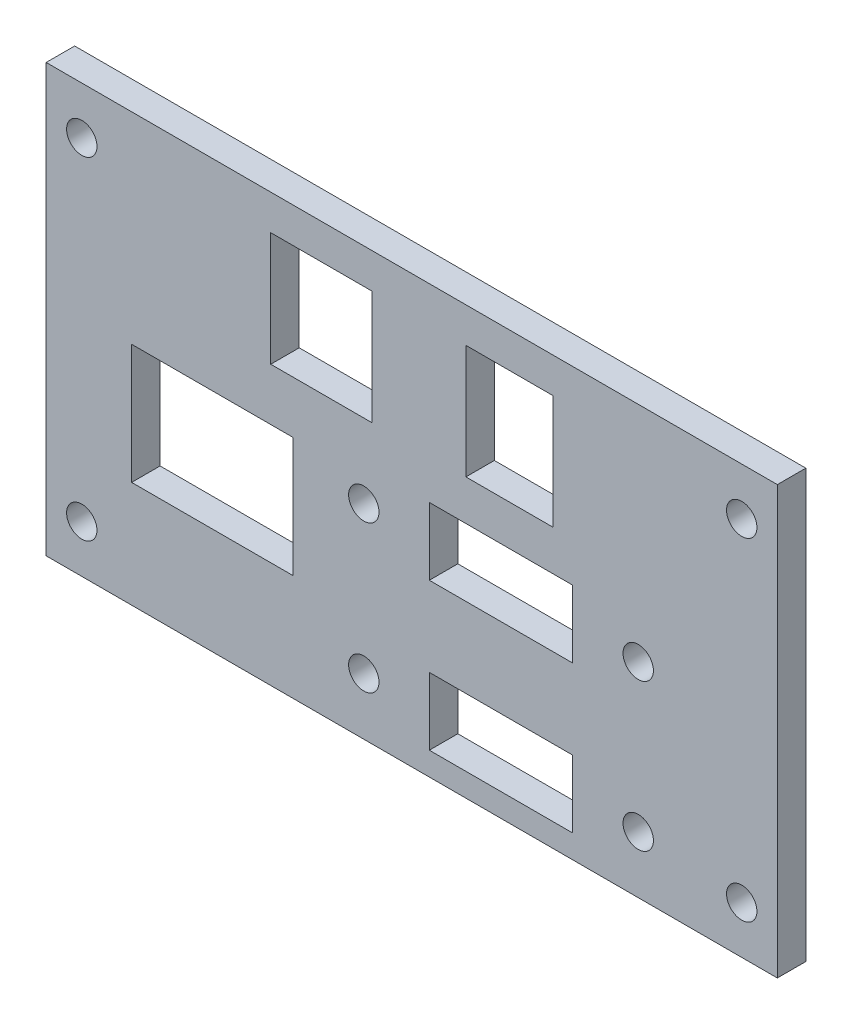
from build123d import *

# Parameters (mm, degrees)
CROQUIS1_W              = 77
CROQUIS1_H              = 45
SALIENTE_EXTRUIR1_DEPTH = 3
CORTAR_EXTRUIR1_REACH   = 5
CROQUIS2_R              = 1.6
CROQUIS2_W              = 17
CROQUIS2_H              = 12.6
CROQUIS2_W_2            = 10.65
CROQUIS2_H_2            = 12
CROQUIS2_W_3            = 9.15
CROQUIS2_W_4            = 15.1
CROQUIS2_H_3            = 7.1


with BuildPart() as part:
    # Croquis1 → Saliente-Extruir1 (new body)
    with BuildSketch(Plane.XY):
        with Locations((38.5, 22.5)):
            Rectangle(CROQUIS1_W, CROQUIS1_H)
    extrude(amount=SALIENTE_EXTRUIR1_DEPTH)

    # Croquis2 → Cortar-Extruir1 (cut, up to next)
    with BuildSketch(Plane.XY.offset(3), mode=Mode.PRIVATE) as cortar_extruir1_sk1:
        with Locations((3.75, 40)):
            Circle(CROQUIS2_R)
    cortar_extruir1_tool1 = extrude(cortar_extruir1_sk1.sketch, amount=-CORTAR_EXTRUIR1_REACH, mode=Mode.PRIVATE) & part.part
    add(cortar_extruir1_tool1.solids().sort_by_distance((3.75, 40, 3))[0], mode=Mode.SUBTRACT)
    # Croquis2 → Cortar-Extruir1 (cut, up to next)
    with BuildSketch(Plane.XY.offset(3), mode=Mode.PRIVATE) as cortar_extruir1_sk2:
        with Locations((3.75, 5)):
            Circle(CROQUIS2_R)
    cortar_extruir1_tool2 = extrude(cortar_extruir1_sk2.sketch, amount=-CORTAR_EXTRUIR1_REACH, mode=Mode.PRIVATE) & part.part
    add(cortar_extruir1_tool2.solids().sort_by_distance((3.75, 5, 3))[0], mode=Mode.SUBTRACT)
    # Croquis2 → Cortar-Extruir1 (cut, up to next)
    with BuildSketch(Plane.XY.offset(3), mode=Mode.PRIVATE) as cortar_extruir1_sk3:
        with Locations((73.25, 5)):
            Circle(CROQUIS2_R)
    cortar_extruir1_tool3 = extrude(cortar_extruir1_sk3.sketch, amount=-CORTAR_EXTRUIR1_REACH, mode=Mode.PRIVATE) & part.part
    add(cortar_extruir1_tool3.solids().sort_by_distance((73.25, 5, 3))[0], mode=Mode.SUBTRACT)
    # Croquis2 → Cortar-Extruir1 (cut, up to next)
    with BuildSketch(Plane.XY.offset(3), mode=Mode.PRIVATE) as cortar_extruir1_sk4:
        with Locations((73.25, 40)):
            Circle(CROQUIS2_R)
    cortar_extruir1_tool4 = extrude(cortar_extruir1_sk4.sketch, amount=-CORTAR_EXTRUIR1_REACH, mode=Mode.PRIVATE) & part.part
    add(cortar_extruir1_tool4.solids().sort_by_distance((73.25, 40, 3))[0], mode=Mode.SUBTRACT)
    # Croquis2 → Cortar-Extruir1 (cut, up to next)
    with BuildSketch(Plane.XY.offset(3), mode=Mode.PRIVATE) as cortar_extruir1_sk5:
        with Locations((33.45, 21.5)):
            Circle(CROQUIS2_R)
    cortar_extruir1_tool5 = extrude(cortar_extruir1_sk5.sketch, amount=-CORTAR_EXTRUIR1_REACH, mode=Mode.PRIVATE) & part.part
    add(cortar_extruir1_tool5.solids().sort_by_distance((33.45, 21.5, 3))[0], mode=Mode.SUBTRACT)
    # Croquis2 → Cortar-Extruir1 (cut, up to next)
    with BuildSketch(Plane.XY.offset(3), mode=Mode.PRIVATE) as cortar_extruir1_sk6:
        with Locations((33.45, 6)):
            Circle(CROQUIS2_R)
    cortar_extruir1_tool6 = extrude(cortar_extruir1_sk6.sketch, amount=-CORTAR_EXTRUIR1_REACH, mode=Mode.PRIVATE) & part.part
    add(cortar_extruir1_tool6.solids().sort_by_distance((33.45, 6, 3))[0], mode=Mode.SUBTRACT)
    # Croquis2 → Cortar-Extruir1 (cut, up to next)
    with BuildSketch(Plane.XY.offset(3), mode=Mode.PRIVATE) as cortar_extruir1_sk7:
        with Locations((62.35, 21.5)):
            Circle(CROQUIS2_R)
    cortar_extruir1_tool7 = extrude(cortar_extruir1_sk7.sketch, amount=-CORTAR_EXTRUIR1_REACH, mode=Mode.PRIVATE) & part.part
    add(cortar_extruir1_tool7.solids().sort_by_distance((62.35, 21.5, 3))[0], mode=Mode.SUBTRACT)
    # Croquis2 → Cortar-Extruir1 (cut, up to next)
    with BuildSketch(Plane.XY.offset(3), mode=Mode.PRIVATE) as cortar_extruir1_sk8:
        with Locations((62.35, 6)):
            Circle(CROQUIS2_R)
    cortar_extruir1_tool8 = extrude(cortar_extruir1_sk8.sketch, amount=-CORTAR_EXTRUIR1_REACH, mode=Mode.PRIVATE) & part.part
    add(cortar_extruir1_tool8.solids().sort_by_distance((62.35, 6, 3))[0], mode=Mode.SUBTRACT)
    # Croquis2 → Cortar-Extruir1 (cut, up to next)
    with BuildSketch(Plane.XY.offset(3), mode=Mode.PRIVATE) as cortar_extruir1_sk9:
        with Locations((17.5, 17.5)):
            Rectangle(CROQUIS2_W, CROQUIS2_H)
    cortar_extruir1_tool9 = extrude(cortar_extruir1_sk9.sketch, amount=-CORTAR_EXTRUIR1_REACH, mode=Mode.PRIVATE) & part.part
    add(cortar_extruir1_tool9.solids().sort_by_distance((17.5, 17.5, 3))[0], mode=Mode.SUBTRACT)
    # Croquis2 → Cortar-Extruir1 (cut, up to next)
    with BuildSketch(Plane.XY.offset(3), mode=Mode.PRIVATE) as cortar_extruir1_sk10:
        with Locations((28.975, 35.3)):
            Rectangle(CROQUIS2_W_2, CROQUIS2_H_2)
    cortar_extruir1_tool10 = extrude(cortar_extruir1_sk10.sketch, amount=-CORTAR_EXTRUIR1_REACH, mode=Mode.PRIVATE) & part.part
    add(cortar_extruir1_tool10.solids().sort_by_distance((28.975, 35.3, 3))[0], mode=Mode.SUBTRACT)
    # Croquis2 → Cortar-Extruir1 (cut, up to next)
    with BuildSketch(Plane.XY.offset(3), mode=Mode.PRIVATE) as cortar_extruir1_sk11:
        with Locations((48.775, 35.3)):
            Rectangle(CROQUIS2_W_3, CROQUIS2_H_2)
    cortar_extruir1_tool11 = extrude(cortar_extruir1_sk11.sketch, amount=-CORTAR_EXTRUIR1_REACH, mode=Mode.PRIVATE) & part.part
    add(cortar_extruir1_tool11.solids().sort_by_distance((48.775, 35.3, 3))[0], mode=Mode.SUBTRACT)
    # Croquis2 → Cortar-Extruir1 (cut, up to next)
    with BuildSketch(Plane.XY.offset(3), mode=Mode.PRIVATE) as cortar_extruir1_sk12:
        with Locations((47.9, 21.5)):
            Rectangle(CROQUIS2_W_4, CROQUIS2_H_3)
    cortar_extruir1_tool12 = extrude(cortar_extruir1_sk12.sketch, amount=-CORTAR_EXTRUIR1_REACH, mode=Mode.PRIVATE) & part.part
    add(cortar_extruir1_tool12.solids().sort_by_distance((47.9, 21.5, 3))[0], mode=Mode.SUBTRACT)
    # Croquis2 → Cortar-Extruir1 (cut, up to next)
    with BuildSketch(Plane.XY.offset(3), mode=Mode.PRIVATE) as cortar_extruir1_sk13:
        with Locations((47.9, 6)):
            Rectangle(CROQUIS2_W_4, CROQUIS2_H_3)
    cortar_extruir1_tool13 = extrude(cortar_extruir1_sk13.sketch, amount=-CORTAR_EXTRUIR1_REACH, mode=Mode.PRIVATE) & part.part
    add(cortar_extruir1_tool13.solids().sort_by_distance((47.9, 6, 3))[0], mode=Mode.SUBTRACT)


solid = part.part
